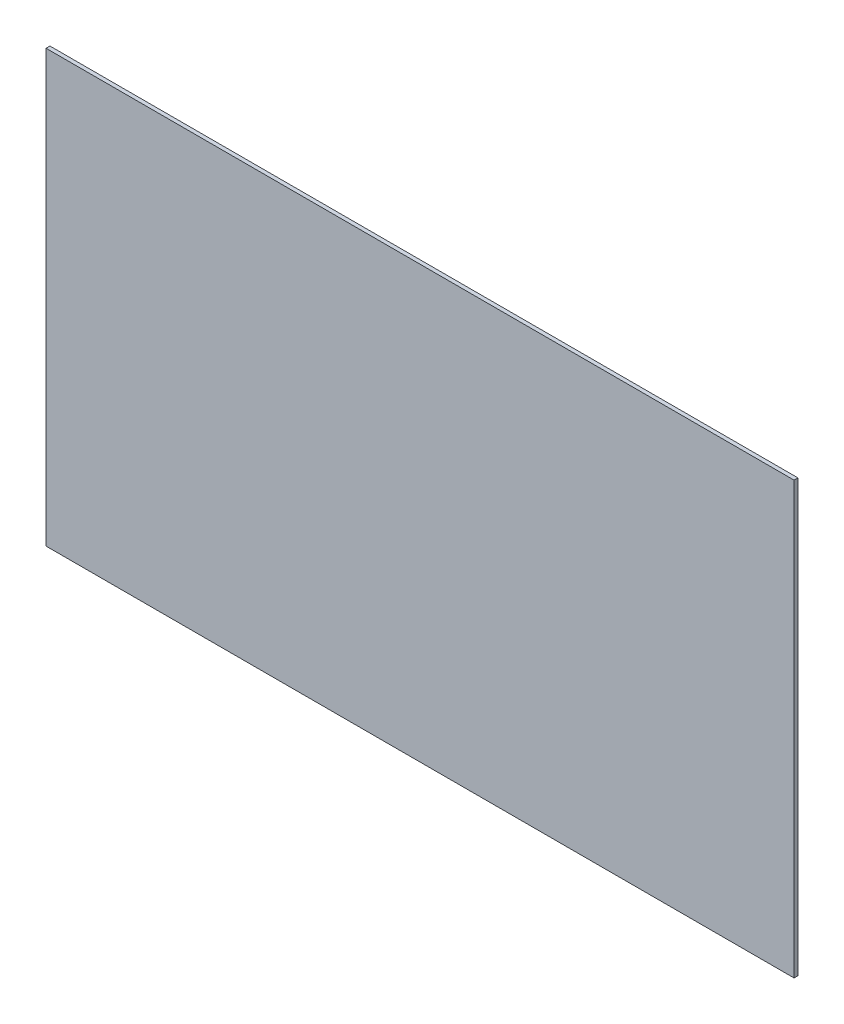
from build123d import *

# Parameters (mm, degrees)
SKETCH1_W           = 1828.8
SKETCH1_H           = 1054.1
BOSS_EXTRUDE1_DEPTH = 9.525


with BuildPart() as part:
    # Sketch1 → Boss-Extrude1 (new body)
    with BuildSketch(Plane.XY):
        with Locations((914.4, 527.05)):
            Rectangle(SKETCH1_W, SKETCH1_H)
    extrude(amount=BOSS_EXTRUDE1_DEPTH)


solid = part.part
